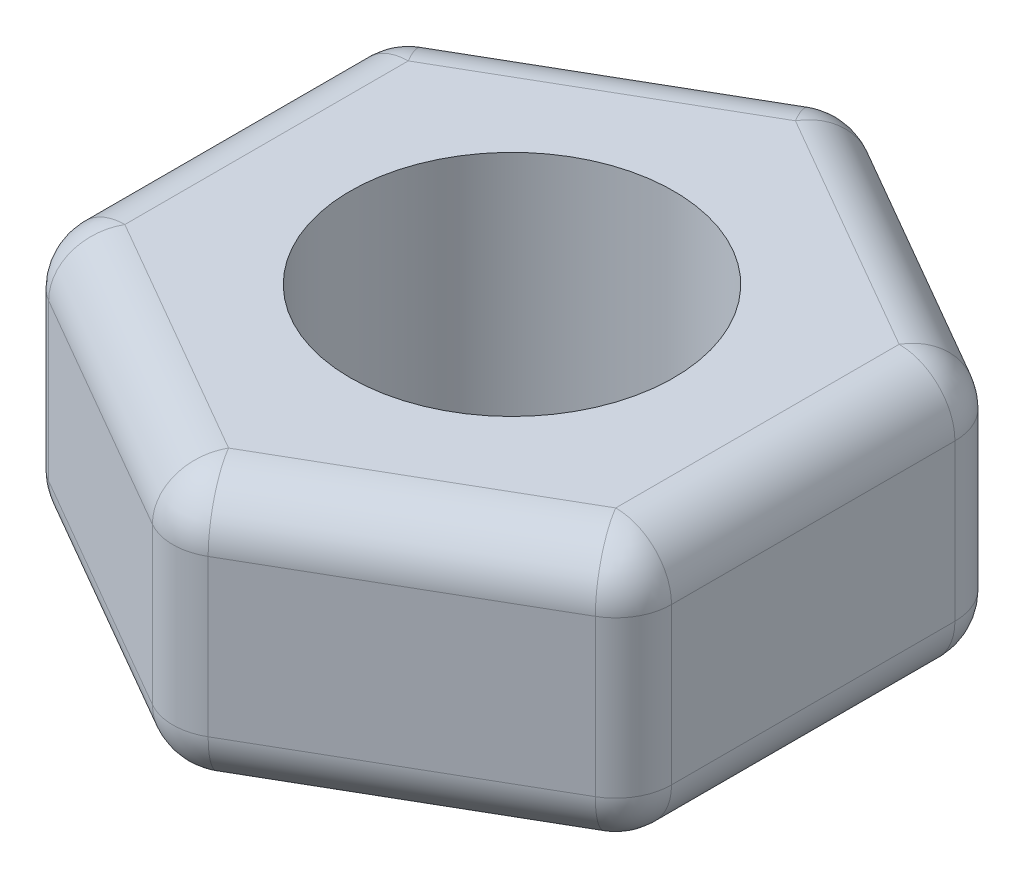
from build123d import *

# Parameters (mm, degrees)
SKETCH1_R           = 1.45
BOSS_EXTRUDE1_DEPTH = 2.4
FILLET1_R           = 0.5


with BuildPart() as part:
    # Sketch1 → Boss-Extrude1 (new body)
    with BuildSketch(Plane(origin=(0, 0, 0), x_dir=(1, 0, 0), z_dir=(0, 1, 0))):
        Polygon((0, 3.117691454), (-2.7, 1.558845727), (-2.7, -1.558845727), (0, -3.117691454), (2.7, -1.558845727), (2.7, 1.558845727), align=None)
        Circle(SKETCH1_R, mode=Mode.SUBTRACT)
    extrude(amount=BOSS_EXTRUDE1_DEPTH)

    # Fillet1
    fillet1_edges = [part.edges().sort_by_distance(p)[0] for p in [
        (2.7, 1.2, -1.558845727),
        (2.7, 1.2, 1.558845727),
        (0, 1.2, 3.117691454),
        (-2.7, 1.2, 1.558845727),
        (-2.7, 1.2, -1.558845727),
        (0, 1.2, -3.117691454),
        (-2.7, 2.4, 0),
        (-1.35, 2.4, 2.33826859),
        (1.35, 2.4, 2.33826859),
        (2.7, 2.4, 0),
        (1.35, 2.4, -2.33826859),
        (2.7, 0, 0),
        (1.35, 0, 2.33826859),
        (-1.35, 0, 2.33826859),
        (-2.7, 0, 0),
        (-1.35, 0, -2.33826859),
        (1.35, 0, -2.33826859),
        (-1.35, 2.4, -2.33826859),
    ]]
    fillet(fillet1_edges, radius=FILLET1_R)


solid = part.part
